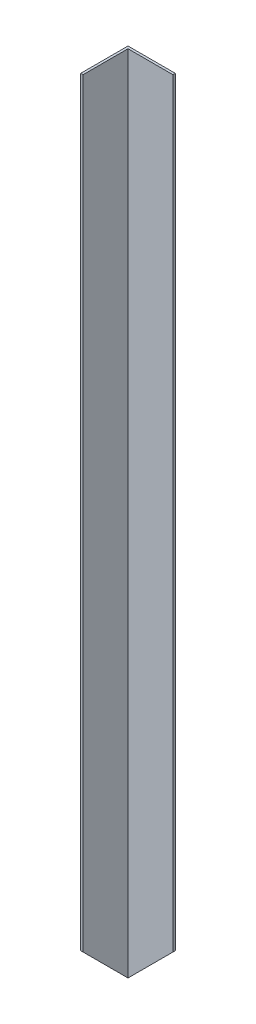
from build123d import *

# Parameters (mm, degrees)
BOSS_EXTRU_1_DEPTH      = 682
ENL_V_MAT_EXTRU_1_DEPTH = 590
ENL_V_MAT_EXTRU_2_DEPTH = 590


with BuildPart() as part:
    # Esquisse1 → Boss.-Extru.1 (new body)
    with BuildSketch(Plane(origin=(0, 0, 0), x_dir=(1, 0, 0), z_dir=(0, 1, 0))):
        Polygon((-20, 20.113636364), (20, 20.113636364), (20, 18.113636364), (-18, 18.113636364), (-18, -19.886363636), (-20, -19.886363636), align=None)
    extrude(amount=BOSS_EXTRU_1_DEPTH)

    # Esquisse2 → Enlèv. mat.-Extru.1 (cut)
    with BuildSketch(Plane(origin=(0, 0, -20.113636364), x_dir=(-1, 0, 0), z_dir=(0, 0, -1))):
        Polygon((20, 0), (-20, 40), (-20, 0), align=None)
    extrude(amount=-ENL_V_MAT_EXTRU_1_DEPTH, mode=Mode.SUBTRACT)

    # Esquisse3 → Enlèv. mat.-Extru.2 (cut)
    with BuildSketch(Plane.ZY.offset(20)):
        Polygon((-20.113636364, 0), (19.886363636, 40), (19.886363636, 0), align=None)
    extrude(amount=-ENL_V_MAT_EXTRU_2_DEPTH, mode=Mode.SUBTRACT)


solid = part.part
